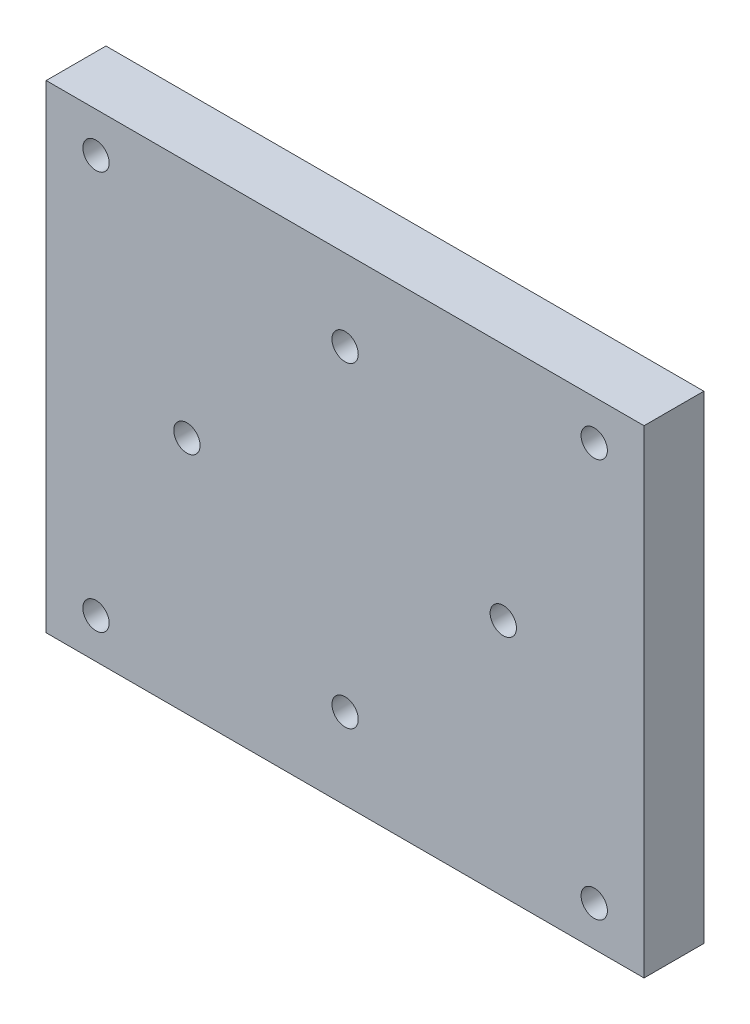
from build123d import *

# Parameters (mm, degrees)
SKETCH1_W           = 60
SKETCH1_H           = 48
SKETCH1_R           = 1.32
BOSS_EXTRUDE1_DEPTH = 6
SKETCH2_R           = 3.25
CUT_EXTRUDE1_DEPTH  = 4


with BuildPart() as part:
    # Sketch1 → Boss-Extrude1 (new body)
    with BuildSketch(Plane.XY):
        Rectangle(SKETCH1_W, SKETCH1_H)
        with Locations((0, -15.875)):
            Circle(SKETCH1_R, mode=Mode.SUBTRACT)
        with Locations((-15.875, 0)):
            Circle(SKETCH1_R, mode=Mode.SUBTRACT)
        with Locations((0, 15.875)):
            Circle(SKETCH1_R, mode=Mode.SUBTRACT)
        with Locations((15.875, 0)):
            Circle(SKETCH1_R, mode=Mode.SUBTRACT)
        with Locations((-25, 20)):
            Circle(SKETCH1_R, mode=Mode.SUBTRACT)
        with Locations((25, 20)):
            Circle(SKETCH1_R, mode=Mode.SUBTRACT)
        with Locations((25, -20)):
            Circle(SKETCH1_R, mode=Mode.SUBTRACT)
        with Locations((-25, -20)):
            Circle(SKETCH1_R, mode=Mode.SUBTRACT)
    extrude(amount=BOSS_EXTRUDE1_DEPTH)

    # Sketch2 → Cut-Extrude1 (cut)
    with BuildSketch(Plane(origin=(0, 0, 0), x_dir=(-1, 0, 0), z_dir=(0, 0, -1))):
        with Locations((0, 15.875)):
            Circle(SKETCH2_R)
        with Locations((15.875, 0)):
            Circle(SKETCH2_R)
        with Locations((0, -15.875)):
            Circle(SKETCH2_R)
        with Locations((-15.875, 0)):
            Circle(SKETCH2_R)
    extrude(amount=-CUT_EXTRUDE1_DEPTH, mode=Mode.SUBTRACT)


solid = part.part
